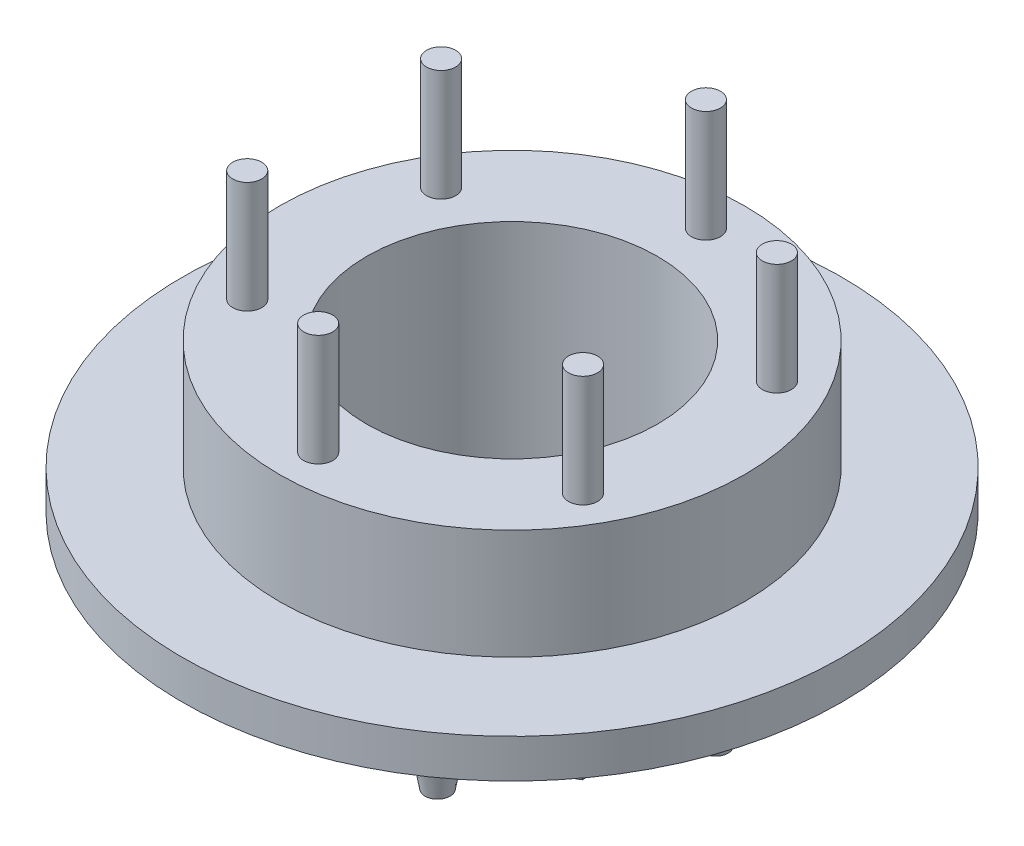
from build123d import *

# Parameters (mm, degrees)
SKETCH1_R           = 12
SKETCH1_R_2         = 7.5
BOSS_EXTRUDE1_DEPTH = 10.875
SKETCH2_R           = 0.75
BOSS_EXTRUDE2_DEPTH = 5.75
SKETCH3_R           = 7.5
BOSS_EXTRUDE3_DEPTH = 2
SKETCH4_W           = 5
SKETCH4_H           = 2
SKETCH5_R           = 1
BOSS_EXTRUDE4_DEPTH = 2
BOSS_EXTRUDE4_TAPER = 10


with BuildPart() as part:
    # Sketch1 → Boss-Extrude1 (new body)
    with BuildSketch(Plane(origin=(0, 0, 0), x_dir=(1, 0, 0), z_dir=(0, 1, 0))):
        Circle(SKETCH1_R)
        Circle(SKETCH1_R_2, mode=Mode.SUBTRACT)
    extrude(amount=BOSS_EXTRUDE1_DEPTH)

    # Sketch2 → Boss-Extrude2 (add)
    with BuildSketch(Plane(origin=(0, 10.875, 0), x_dir=(1, 0, 0), z_dir=(0, 1, 0))):
        with Locations((0, 10)):
            Circle(SKETCH2_R)
        with Locations((-8.660254038, 5)):
            Circle(SKETCH2_R)
        with Locations((-8.660254038, -5)):
            Circle(SKETCH2_R)
        with Locations((0, -10)):
            Circle(SKETCH2_R)
        with Locations((8.660254038, -5)):
            Circle(SKETCH2_R)
        with Locations((8.660254038, 5)):
            Circle(SKETCH2_R)
    extrude(amount=BOSS_EXTRUDE2_DEPTH)

    # Sketch3 → Boss-Extrude3 (add)
    with BuildSketch(Plane(origin=(0, 0, 0), x_dir=(-1, 0, 0), z_dir=(0, -1, 0))):
        Polygon((0, -9.9), (8.573651497, -4.95), (8.573651497, 4.95), (0, 9.9), (-8.573651497, 4.95), (-8.573651497, -4.95), align=None)
        Circle(SKETCH3_R, mode=Mode.SUBTRACT)
    extrude(amount=BOSS_EXTRUDE3_DEPTH)

    # Sketch4 → Revolve1 (revolve)
    with BuildSketch(Plane.XY):
        with Locations((14.5, 4.2)):
            Rectangle(SKETCH4_W, SKETCH4_H)
    revolve(axis=Axis((0, -2, 0), (0, 1, 0)))

    # Sketch5 → Boss-Extrude4 (add)
    with BuildSketch(Plane.XZ):
        with Locations((-5.25, 9.09326674)):
            Circle(SKETCH5_R)
        with Locations((5.25, 9.09326674)):
            Circle(SKETCH5_R)
        with Locations((10.5, 0)):
            Circle(SKETCH5_R)
        with Locations((5.25, -9.09326674)):
            Circle(SKETCH5_R)
        with Locations((-5.25, -9.09326674)):
            Circle(SKETCH5_R)
        with Locations((-10.5, 0)):
            Circle(SKETCH5_R)
    extrude(amount=BOSS_EXTRUDE4_DEPTH, taper=BOSS_EXTRUDE4_TAPER)


solid = part.part
